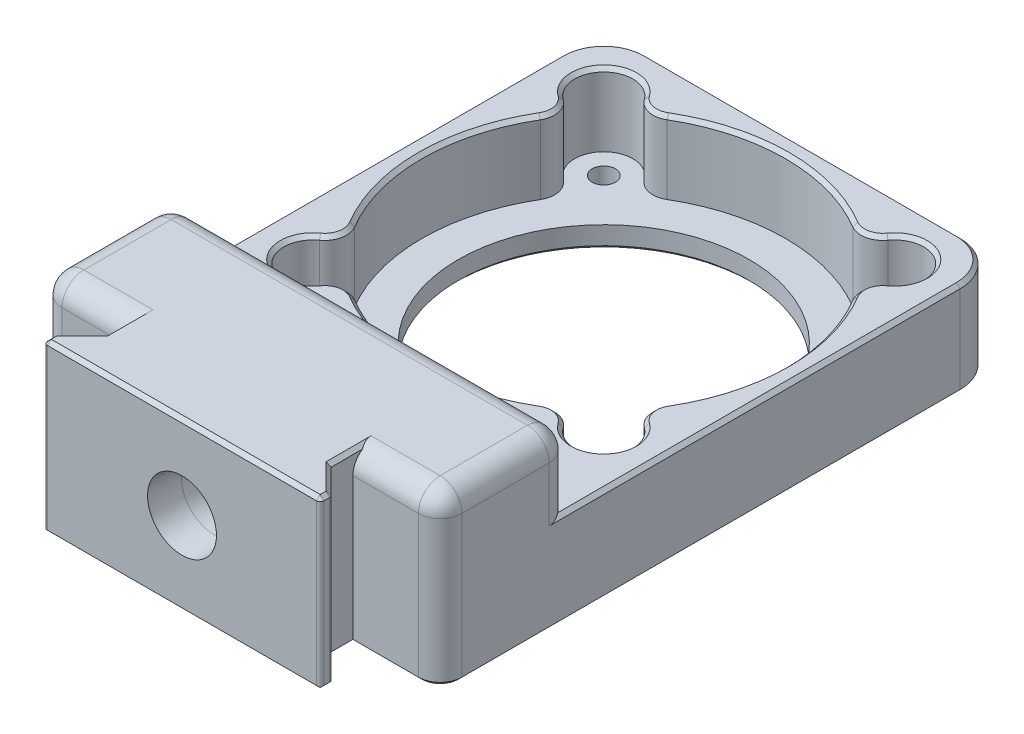
from build123d import *

# Parameters (mm, degrees)
SKETCH3_W                = 55
SKETCH3_H                = 77.5
SKETCH3_R                = 20
SKETCH3_R_2              = 1.6
MOUNTINGFLANGE_DEPTH     = 3
SKETCH4_W                = 55
SKETCH4_H                = 77.5
SKETCH4_R                = 25
PICTUREFRAME_DEPTH       = 10
SKETCH5_R                = 4
SCREWCOUNTERBORE_DEPTH   = 11
FILLETSCREWCOUNTERBORE_R = 3
FILLETOUTERCORNERS_R     = 6
SKETCH6_W                = 55
SKETCH6_H                = 18
BASE_DEPTH               = 10
ARCABASE_DEPTH           = 23
SKETCH7_R                = 4.4323
TRIPODMOUNT_DEPTH        = 12
FILLETLARGE_R            = 3
CHAMFERBOTTOM_SIZE       = 0.5
CHAMFERTOP_SIZE          = 0.5
CHAMFERTRIPODMOUNT_SIZE  = 0.3048
CHAMFERTRIPODMOUNT_SIZE2 = 4.358843075
FILLETARCABASE_R         = 0.5
CHAMFER1_SIZE            = 0.5


with BuildPart() as part:
    # Sketch3 → MountingFlange (new body)
    with BuildSketch(Plane(origin=(0, 0, 0), x_dir=(1, 0, 0), z_dir=(0, 1, 0))):
        with Locations((0, -11.25)):
            Rectangle(SKETCH3_W, SKETCH3_H)
        with Locations(Location((0, 0, 0), (0, 0, 270))):  # turned: the seam where the file's is
            Circle(SKETCH3_R, mode=Mode.SUBTRACT)
        with Locations(Location((-20, 20, 0), (0, 0, 270))):  # turned: the seam where the file's is
            Circle(SKETCH3_R_2, mode=Mode.SUBTRACT)
        with Locations(Location((20, 20, 0), (0, 0, 270))):  # turned: the seam where the file's is
            Circle(SKETCH3_R_2, mode=Mode.SUBTRACT)
        with Locations(Location((20, -20, 0), (0, 0, 270))):  # turned: the seam where the file's is
            Circle(SKETCH3_R_2, mode=Mode.SUBTRACT)
        with Locations(Location((-20, -20, 0), (0, 0, 270))):  # turned: the seam where the file's is
            Circle(SKETCH3_R_2, mode=Mode.SUBTRACT)
    extrude(amount=MOUNTINGFLANGE_DEPTH)

    # Sketch4 → PictureFrame (add)
    with BuildSketch(Plane(origin=(0, 3, 0), x_dir=(1, 0, 0), z_dir=(0, 1, 0))):
        with Locations((0, -11.25)):
            Rectangle(SKETCH4_W, SKETCH4_H)
        with Locations(Location((0, 0, 0), (0, 0, 270))):  # turned: the seam where the file's is
            Circle(SKETCH4_R, mode=Mode.SUBTRACT)
    extrude(amount=PICTUREFRAME_DEPTH)

    # Sketch5 → ScrewCounterbore (cut, through all)
    with BuildSketch(Plane.XZ.offset(-3)):
        with Locations((20, -20)):
            Circle(SKETCH5_R)
        with Locations((-20, -20)):
            Circle(SKETCH5_R)
        with Locations((-20, 20)):
            Circle(SKETCH5_R)
        with Locations((20, 20)):
            Circle(SKETCH5_R)
    extrude(amount=-SCREWCOUNTERBORE_DEPTH, mode=Mode.SUBTRACT)

    # FilletScrewCounterbore
    filletscrewcounterbore_edges = [part.edges().sort_by_distance(p)[0] for p in [
        (16.095976426, 8, 19.129023574),
        (19.129023574, 8, 16.095976426),
        (-19.129023574, 8, 16.095976426),
        (-16.095976426, 8, 19.129023574),
        (-16.095976426, 8, -19.129023574),
        (-19.129023574, 8, -16.095976426),
        (19.129023574, 8, -16.095976426),
        (16.095976426, 8, -19.129023574),
    ]]
    fillet(filletscrewcounterbore_edges, radius=FILLETSCREWCOUNTERBORE_R)

    # FilletOuterCorners
    filletoutercorners_edges = [part.edges().sort_by_distance(p)[0] for p in [
        (-27.5, 6.5, -27.5),
        (27.5, 6.5, -27.5),
    ]]
    fillet(filletoutercorners_edges, radius=FILLETOUTERCORNERS_R)

    # Sketch6 → Base (add)
    with BuildSketch(Plane(origin=(0, 13, 0), x_dir=(1, 0, 0), z_dir=(0, 1, 0))):
        with Locations((0, -41)):
            Rectangle(SKETCH6_W, SKETCH6_H)
    extrude(amount=BASE_DEPTH)

    # Sketch8 → ArcaBase (add)
    with BuildSketch(Plane(origin=(0, 23, 0), x_dir=(1, 0, 0), z_dir=(0, 1, 0))):
        Polygon((-15.5, -53), (-19, -56.5), (-19, -58), (19, -58), (19, -56.5), (15.5, -53), (15.5, -50), (-15.5, -50), align=None)
    extrude(amount=-ARCABASE_DEPTH)

    # Sketch7 → TripodMount (cut)
    with BuildSketch(Plane.XY.offset(58)):
        with Locations((0, 11.5)):
            Circle(SKETCH7_R)
    extrude(amount=-TRIPODMOUNT_DEPTH, mode=Mode.SUBTRACT)

    # FilletLarge
    filletlarge_edges = [part.edges().sort_by_distance(p)[0] for p in [
        (-27.5, 18, 32),
        (27.5, 18, 32),
        (-27.5, 23, 41),
        (-21.5, 23, 50),
        (27.5, 23, 41),
        (0, 23, 32),
        (21.5, 23, 50),
        (27.5, 11.5, 50),
        (-27.5, 11.5, 50),
    ]]
    fillet(filletlarge_edges, radius=FILLETLARGE_R)

    # ChamferBottom
    chamferbottom_edges = [part.edges().sort_by_distance(p)[0] for p in [
        (0, 0, -20),
        (0, 0, -27.5),
        (-27.5, 0, 12.75),
        (-25.742640687, 0, -25.742640687),
        (25.742640687, 0, -25.742640687),
        (20, 0, -21.6),
        (20, 0, 50),
        (-15.5, 0, 51.5),
        (15.5, 0, 51.5),
        (17.25, 0, 54.75),
        (19, 0, 57.25),
        (0, 0, 58),
        (-19, 0, 57.25),
        (-17.25, 0, 54.75),
        (20, 0, 18.4),
        (27.5, 0, 12.75),
        (-20, 0, 50),
        (-26.621320344, 0, 49.121320344),
        (26.621320344, 0, 49.121320344),
        (-20, 0, 18.4),
        (-20, 0, -21.6),
    ]]
    chamfer(chamferbottom_edges, length=CHAMFERBOTTOM_SIZE)

    # ChamferTop
    chamfertop_edges = [part.edges().sort_by_distance(p)[0] for p in [
        (22.828427125, 13, 22.828427125),
        (0, 13, 25),
        (-22.828427125, 13, 22.828427125),
        (-25, 13, 0),
        (-22.828427125, 13, -22.828427125),
        (0, 13, -25),
        (25, 13, 0),
        (-14.921579234, 13, -21.134173852),
        (-21.134173852, 13, -14.921579234),
        (-21.134173852, 13, 14.921579234),
        (14.921579234, 13, -21.134173852),
        (21.134173852, 13, 14.921579234),
        (14.921579234, 13, 21.134173852),
        (-14.921579234, 13, 21.134173852),
        (21.134173852, 13, -14.921579234),
        (0, 13, -27.5),
        (-27.5, 13, 5.25),
        (-25.742640687, 13, -25.742640687),
        (25.742640687, 13, -25.742640687),
        (27.5, 13, 5.25),
        (22.828427125, 13, -22.828427125),
    ]]
    chamfer(chamfertop_edges, length=CHAMFERTOP_SIZE)

    # ChamferTripodMount
    chamfertripodmount_edges = [part.edges().sort_by_distance(p)[0] for p in [
        (-4.4323, 11.5, 58),
    ]]
    chamfertripodmount_side = [part.faces().sort_by_distance(p)[0] for p in [
        (-18.558383651, 11.75, 58),
    ]]
    chamfer(chamfertripodmount_edges, length=CHAMFERTRIPODMOUNT_SIZE, length2=CHAMFERTRIPODMOUNT_SIZE2, reference=chamfertripodmount_side[0])

    # FilletArcaBase
    filletarcabase_edges = [part.edges().sort_by_distance(p)[0] for p in [
        (-19, 11.75, 56.5),
        (-19, 11.75, 58),
        (19, 11.75, 58),
        (19, 11.75, 56.5),
    ]]
    fillet(filletarcabase_edges, radius=FILLETARCABASE_R)

    # Chamfer1
    chamfer1_edges = [part.edges().sort_by_distance(p)[0] for p in [
        (-15.5, 23, 51.5),
        (-17.176776695, 23, 54.676776695),
        (15.5, 23, 51.5),
        (0, 23, 58),
        (-19, 23, 57.103553391),
        (19, 23, 57.103553391),
        (17.176776695, 23, 54.676776695),
        (-18.853553391, 23, 57.853553391),
        (-18.961939766, 23, 56.515765065),
        (18.961939766, 23, 56.515765065),
        (18.853553391, 23, 57.853553391),
    ]]
    chamfer(chamfer1_edges, length=CHAMFER1_SIZE)


solid = part.part
